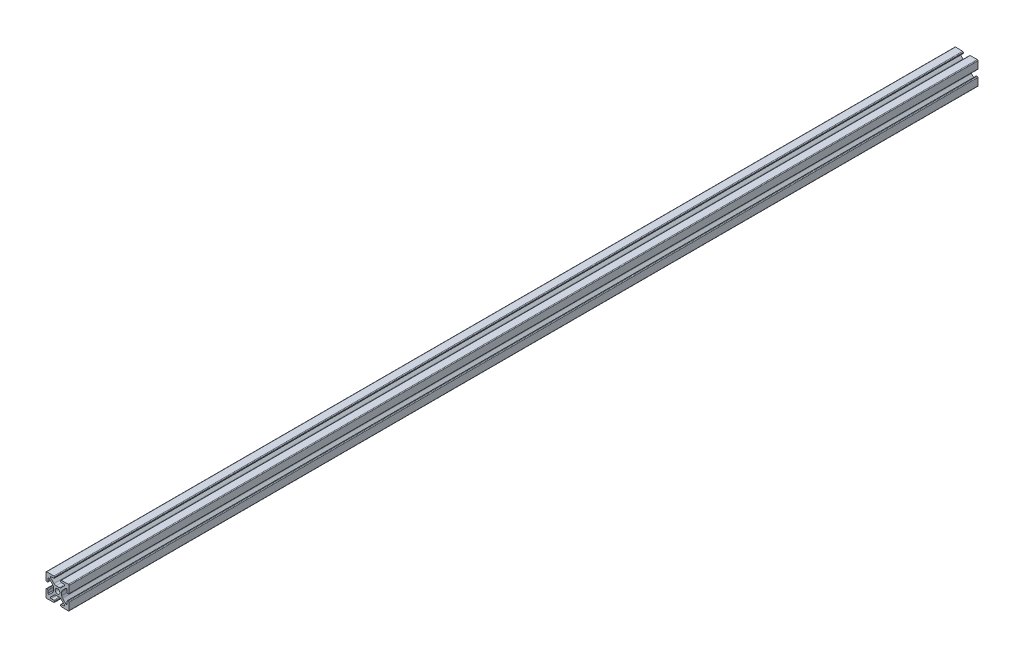
from build123d import *

# Parameters (mm, degrees)
SKETCH1_R           = 2.5527
BOSS_EXTRUDE1_DEPTH = 1000


with BuildPart() as part:
    # Sketch1 → Boss-Extrude1 (new body)
    with BuildSketch(Plane(origin=(0, 0, 0), x_dir=(-1, 0, 0), z_dir=(0, 0, 1))):
        with BuildLine():
            Line((12.7, -11.928012126), (12.597888134, -4.12768572))
            ThreePointArc((12.597888134, -4.12768572), (12.37123073, -3.595329652), (11.835953416, -3.375659992))
            Line((11.835953416, -3.375659992), (11.211638876, -3.375659992))
            ThreePointArc((11.211638876, -3.375659992), (10.672823509, -3.598844625), (10.449638876, -4.137659992))
            Line((10.449638876, -4.137659992), (10.449638876, -7.011443668))
            ThreePointArc((10.449638876, -7.011443668), (9.979243652, -7.715439871), (9.148823509, -7.550259035))
            Line((9.148823509, -7.550259035), (5.512177529, -3.913613055))
            ThreePointArc((5.512177529, -3.913613055), (4.823848516, -2.878310338), (4.582238867, -1.658772178))
            Line((4.582238867, -1.658772178), (4.582238867, 1.658772182))
            ThreePointArc((4.582238867, 1.658772182), (4.823848516, 2.878310345), (5.512177531, 3.913613063))
            Line((5.512177531, 3.913613063), (9.148823511, 7.550259043))
            ThreePointArc((9.148823511, 7.550259043), (9.979243654, 7.71543988), (10.449638878, 7.011443676))
            Line((10.449638878, 7.011443676), (10.449638878, 4.13766))
            ThreePointArc((10.449638878, 4.13766), (10.672823511, 3.598844633), (11.211638878, 3.37566))
            Line((11.211638878, 3.37566), (11.835953418, 3.37566))
            ThreePointArc((11.835953418, 3.37566), (12.37123073, 3.595329661), (12.597888134, 4.127685728))
            Line((12.597888134, 4.127685728), (12.7, 11.928012134))
            ThreePointArc((12.7, 11.928012134), (12.476881698, 12.476881702), (11.928012128, 12.7))
            Line((11.928012128, 12.7), (4.127685722, 12.597888134))
            ThreePointArc((4.127685722, 12.597888134), (3.595329654, 12.37123073), (3.375659994, 11.835953416))
            Line((3.375659994, 11.835953416), (3.375659994, 11.211638876))
            ThreePointArc((3.375659994, 11.211638876), (3.598844627, 10.672823509), (4.137659994, 10.449638876))
            Line((4.137659994, 10.449638876), (7.01144367, 10.449638876))
            ThreePointArc((7.01144367, 10.449638876), (7.715461217, 9.979192126), (7.550180161, 9.148744642))
            Line((7.550180161, 9.148744642), (3.913534181, 5.512098662))
            ThreePointArc((3.913534181, 5.512098662), (2.878231464, 4.823769649), (1.658693304, 4.58216))
            Line((1.658693304, 4.58216), (-1.668625226, 4.58216))
            ThreePointArc((-1.668625226, 4.58216), (-2.883645124, 4.823842484), (-3.913689257, 5.51209597))
            Line((-3.913689257, 5.51209597), (-7.55033792, 9.148744633))
            ThreePointArc((-7.55033792, 9.148744633), (-7.715518756, 9.979164775), (-7.011522552, 10.44956))
            Line((-7.011522552, 10.44956), (-4.137738876, 10.44956))
            ThreePointArc((-4.137738876, 10.44956), (-3.598923509, 10.672744633), (-3.375738876, 11.21156))
            Line((-3.375738876, 11.21156), (-3.375738876, 11.83587454))
            ThreePointArc((-3.375738876, 11.83587454), (-3.595408537, 12.371151853), (-4.127764605, 12.597809257))
            Line((-4.127764605, 12.597809257), (-11.928091011, 12.699921124))
            ThreePointArc((-11.928091011, 12.699921124), (-12.47688065, 12.476801773), (-12.7, 11.928012134))
            Line((-12.7, 11.928012134), (-12.597888134, 4.127685728))
            ThreePointArc((-12.597888134, 4.127685728), (-12.37123073, 3.59532966), (-11.835953416, 3.37566))
            Line((-11.835953416, 3.37566), (-11.211638876, 3.37566))
            ThreePointArc((-11.211638876, 3.37566), (-10.672823509, 3.598844633), (-10.449638876, 4.13766))
            Line((-10.449638876, 4.13766), (-10.449638876, 7.011443676))
            ThreePointArc((-10.449638876, 7.011443676), (-9.979243652, 7.71543988), (-9.148823509, 7.550259043))
            Line((-9.148823509, 7.550259043), (-5.512177529, 3.913613063))
            ThreePointArc((-5.512177529, 3.913613063), (-4.823848515, 2.878310347), (-4.582238866, 1.658772187))
            Line((-4.582238866, 1.658772187), (-4.582238866, -1.658772174))
            ThreePointArc((-4.582238866, -1.658772174), (-4.823848515, -2.878310336), (-5.512177529, -3.913613055))
            Line((-5.512177529, -3.913613055), (-9.148823509, -7.550259035))
            ThreePointArc((-9.148823509, -7.550259035), (-9.979243652, -7.715439871), (-10.449638876, -7.011443668))
            Line((-10.449638876, -7.011443668), (-10.449638876, -4.137659992))
            ThreePointArc((-10.449638876, -4.137659992), (-10.672823509, -3.598844625), (-11.211638876, -3.375659992))
            Line((-11.211638876, -3.375659992), (-11.835953416, -3.375659992))
            ThreePointArc((-11.835953416, -3.375659992), (-12.37123073, -3.595329652), (-12.597888134, -4.12768572))
            Line((-12.597888134, -4.12768572), (-12.7, -11.928012126))
            ThreePointArc((-12.7, -11.928012126), (-12.476881704, -12.476881697), (-11.928012136, -12.7))
            Line((-11.928012136, -12.7), (-4.12768573, -12.597888134))
            ThreePointArc((-4.12768573, -12.597888134), (-3.595329662, -12.37123073), (-3.375660002, -11.835953416))
            Line((-3.375660002, -11.835953416), (-3.375660002, -11.211638876))
            ThreePointArc((-3.375660002, -11.211638876), (-3.598844634, -10.672823509), (-4.137660002, -10.449638876))
            Line((-4.137660002, -10.449638876), (-7.011443678, -10.449638876))
            ThreePointArc((-7.011443678, -10.449638876), (-7.715439881, -9.979243652), (-7.550259045, -9.148823509))
            Line((-7.550259045, -9.148823509), (-3.913610382, -5.512174846))
            ThreePointArc((-3.913610382, -5.512174846), (-2.883566249, -4.823921361), (-1.668546352, -4.582238876))
            Line((-1.668546352, -4.582238876), (1.658772179, -4.582238876))
            ThreePointArc((1.658772179, -4.582238876), (2.878310341, -4.823848525), (3.913613059, -5.51217754))
            Line((3.913613059, -5.51217754), (7.550259039, -9.14882352))
            ThreePointArc((7.550259039, -9.14882352), (7.715439864, -9.979243654), (7.011443672, -10.449638876))
            Line((7.011443672, -10.449638876), (4.137659996, -10.449638876))
            ThreePointArc((4.137659996, -10.449638876), (3.598844629, -10.672823509), (3.375659996, -11.211638876))
            Line((3.375659996, -11.211638876), (3.375659996, -11.835953416))
            ThreePointArc((3.375659996, -11.835953416), (3.595329656, -12.37123073), (4.127685724, -12.597888134))
            Line((4.127685724, -12.597888134), (11.92801213, -12.7))
            ThreePointArc((11.92801213, -12.7), (12.476881702, -12.476881699), (12.7, -11.928012126))
        make_face()
        Circle(SKETCH1_R, mode=Mode.SUBTRACT)
    extrude(amount=BOSS_EXTRUDE1_DEPTH)


solid = part.part
